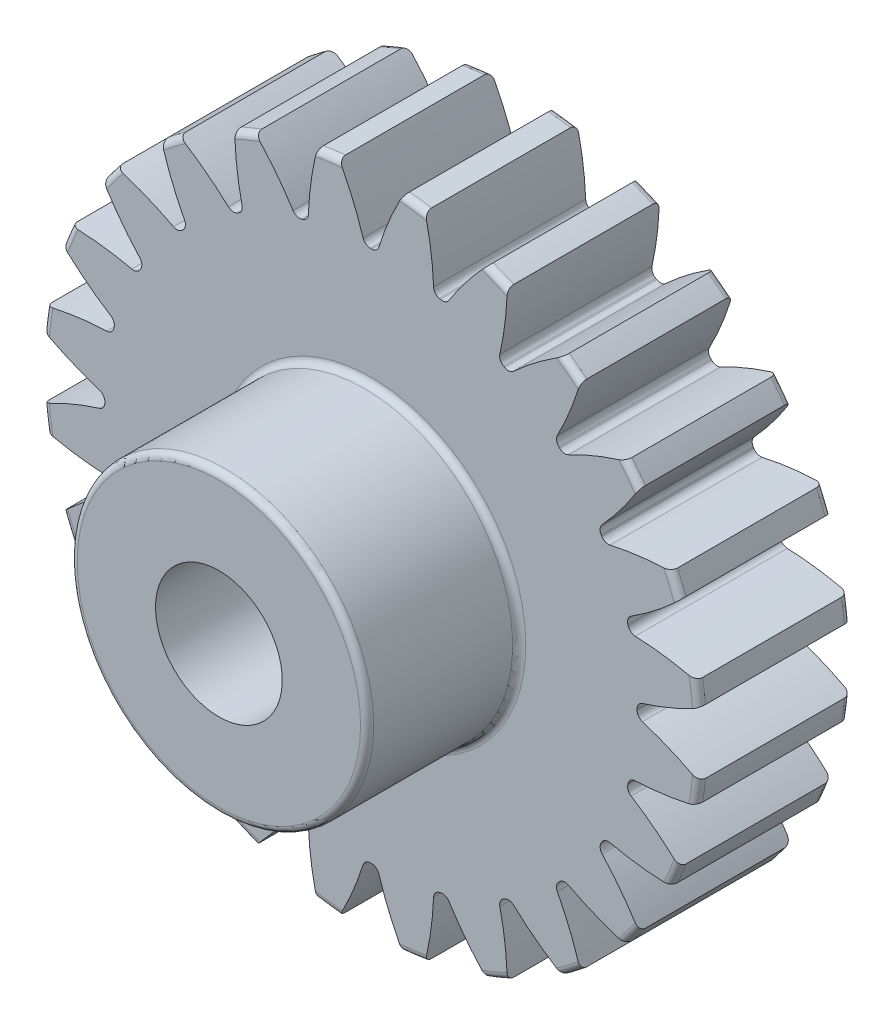
from build123d import *

# Parameters (mm, degrees)
FILLET2_R          = 0.26
CUT_EXTRUDE2_DEPTH = 7.0000001
CIRPATTERN1_COUNT  = 24


with BuildPart() as part:
    # Sketch4 → Revolve1 (revolve)
    with BuildSketch(Plane(origin=(0, 0, 0), x_dir=(0, 0, -1), z_dir=(1, 0, 0))):
        Polygon((-12, 2.5), (-12, 5.85), (-6, 5.85), (-6, 13), (0, 13), (0, 2.5), align=None)
    revolve(axis=Axis((0, 0, 6), (0, 0, 1)))

    # Fillet2
    fillet2_edges = [part.edges().sort_by_distance(p)[0] for p in [
        (0, -13, 0),
        (0, -13, 6),
        (0, -5.85, 6),
        (0, -5.85, 12),
    ]]
    fillet(fillet2_edges, radius=FILLET2_R)

    # Sketch7 → Cut-Extrude2 (cut, through all)
    with BuildSketch(Plane.XY.offset(6)):
        with BuildLine():
            ThreePointArc((-0.024582678, 10.499971223), (0, 10.5), (0.024582678, 10.499971223))
            ThreePointArc((0.024582678, 10.499971223), (0.20282038, 10.558136238), (0.311727142, 10.710750668))
            ThreePointArc((0.311727142, 10.710750668), (0.730427826, 11.84871498), (1.261830524, 12.93861599))
            ThreePointArc((1.261830524, 12.93861599), (0, 13), (-1.261830524, 12.93861599))
            ThreePointArc((-1.261830524, 12.93861599), (-0.730427826, 11.84871498), (-0.311727142, 10.710750668))
            ThreePointArc((-0.311727142, 10.710750668), (-0.20282038, 10.558136238), (-0.024582678, 10.499971223))
        make_face()
    cut_extrude2 = extrude(amount=-CUT_EXTRUDE2_DEPTH, mode=Mode.SUBTRACT)

    # CirPattern1: Cut-Extrude2 ×24 about axis
    cirpattern1_axis = Axis((0, 0, 0), (0, 0, 1))
    for i in range(1, CIRPATTERN1_COUNT):
        add(cut_extrude2.rotate(cirpattern1_axis, i * 360 / CIRPATTERN1_COUNT), mode=Mode.SUBTRACT)


solid = part.part
